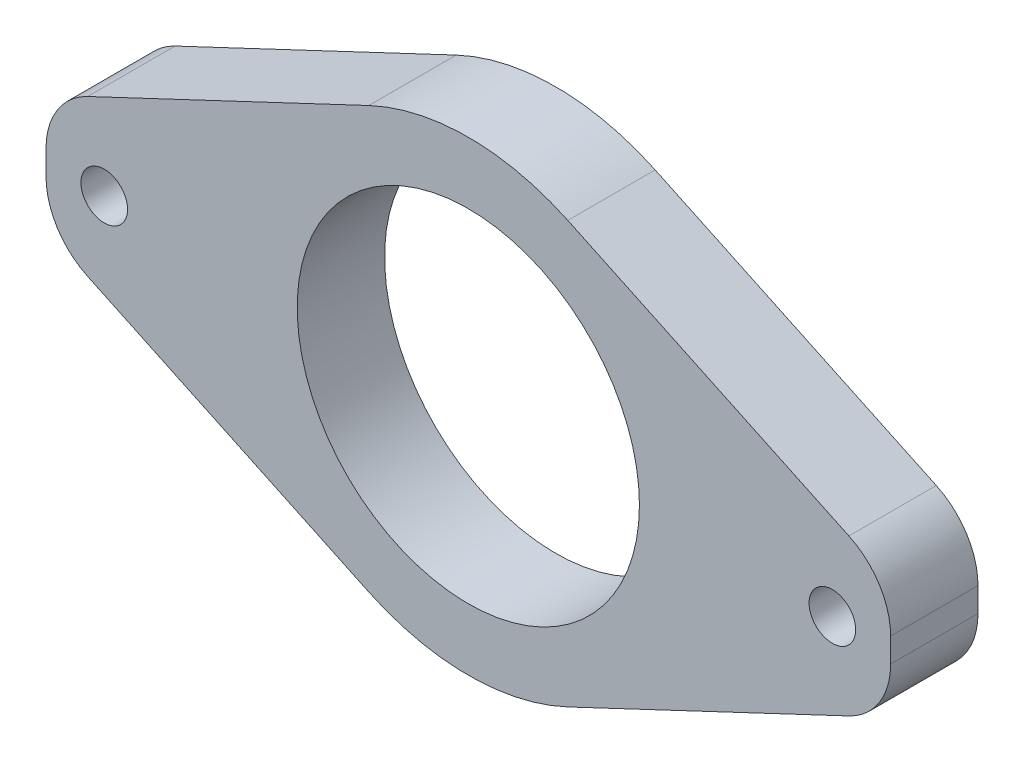
from build123d import *

# Parameters (mm, degrees)
ESBO_O1_R                = 11.75
ESBO_O1_R_2              = 1.6
RESSALTO_EXTRUS_O1_DEPTH = 6
FILETE3_R                = 5


with BuildPart() as part:
    # Esboço1 → Ressalto-extrusão1 (new body)
    with BuildSketch(Plane.XY):
        with BuildLine():
            Line((-15.491933385, -4), (-29, -4))
            Line((-29, -4), (-6.831996166, -14.468027799))
            ThreePointArc((-6.831996166, -14.468027799), (-12.328193669, -10.198805854), (-15.491933385, -4))
        make_face()
        with BuildLine():
            Line((-29, -4), (-15.491933385, -4))
            ThreePointArc((-15.491933385, -4), (0, -16), (15.491933385, -4))
            Line((15.491933385, -4), (29, -4))
            Line((29, -4), (29, 4))
            Line((29, 4), (15.491933385, 4))
            ThreePointArc((15.491933385, 4), (0, 16), (-15.491933385, 4))
            Line((-15.491933385, 4), (-29, 4))
            Line((-29, 4), (-29, -4))
        make_face()
        Circle(ESBO_O1_R, mode=Mode.SUBTRACT)
        with Locations((-25, 0)):
            Circle(ESBO_O1_R_2, mode=Mode.SUBTRACT)
        with Locations((25, 0)):
            Circle(ESBO_O1_R_2, mode=Mode.SUBTRACT)
        with BuildLine():
            Line((-6.831996166, 14.468027799), (-29, 4))
            Line((-29, 4), (-15.491933385, 4))
            ThreePointArc((-15.491933385, 4), (-12.328193669, 10.198805854), (-6.831996166, 14.468027799))
        make_face()
        with BuildLine():
            Line((29, 4), (6.831996166, 14.468027799))
            ThreePointArc((6.831996166, 14.468027799), (12.328193669, 10.198805854), (15.491933385, 4))
            Line((15.491933385, 4), (29, 4))
        make_face()
        with BuildLine():
            ThreePointArc((15.491933385, -4), (12.328193669, -10.198805854), (6.831996166, -14.468027799))
            Line((6.831996166, -14.468027799), (29, -4))
            Line((29, -4), (15.491933385, -4))
        make_face()
    extrude(amount=RESSALTO_EXTRUS_O1_DEPTH)

    # Filete3
    filete3_edges = [part.edges().sort_by_distance(p)[0] for p in [
        (29, 4, 3),
        (29, -4, 3),
        (-29, -4, 3),
        (-29, 4, 3),
    ]]
    fillet(filete3_edges, radius=FILETE3_R)


solid = part.part
